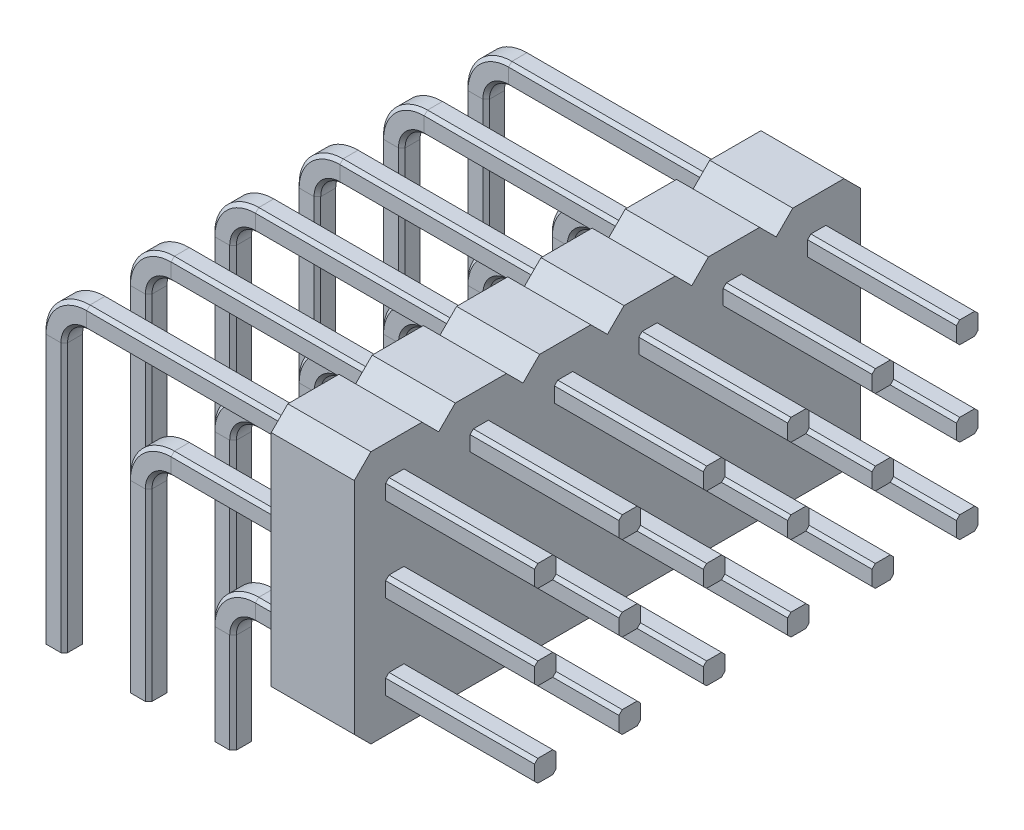
from build123d import *

# Parameters (mm, degrees)
BOSS_EXTRUDE1_DEPTH = 2.5
LPATTERN1_COUNT     = 6
LPATTERN1_PITCH     = 2.54


with BuildPart() as part:
    # Sweep1: sweep along a path in Sketch4
    with BuildLine(Plane.XY) as sweep1_path:
        Line((5.08, 0), (5.08, 3))
        ThreePointArc((5.08, 3), (5.372893219, 3.707106781), (6.08, 4))
        Line((6.08, 4), (14.48, 4))
    # Sketch3 → Sweep1 (sweep)
    with BuildSketch(Plane(origin=(0, 0, 0), x_dir=(1, 0, 0), z_dir=(0, 1, 0))):
        Polygon((5.305, 0.325), (4.855, 0.325), (4.755, 0.225), (4.755, -0.225), (4.855, -0.325), (5.305, -0.325), (5.405, -0.225), (5.405, 0.225), align=None)
    sweep(path=sweep1_path.line)



with BuildPart() as body_2:
    # Sweep2: sweep along a path in Sketch4_3
    with BuildLine(Plane.XY) as sweep2_path:
        Line((2.54, 0), (2.54, 5.54))
        ThreePointArc((2.54, 5.54), (2.832893219, 6.247106781), (3.54, 6.54))
        Line((3.54, 6.54), (14.48, 6.54))
    # Sketch3_3 → Sweep2 (sweep)
    with BuildSketch(Plane(origin=(0, 0, 0), x_dir=(1, 0, 0), z_dir=(0, 1, 0))):
        Polygon((2.765, 0.325), (2.315, 0.325), (2.215, 0.225), (2.215, -0.225), (2.315, -0.325), (2.765, -0.325), (2.865, -0.225), (2.865, 0.225), align=None)
    sweep(path=sweep2_path.line)


with BuildPart() as body_3:
    # Sweep3: sweep along a path in Sketch4_4
    with BuildLine(Plane.XY) as sweep3_path:
        Line((0, 0), (0, 8.08))
        ThreePointArc((0, 8.08), (0.292893219, 8.787106781), (1, 9.08))
        Line((1, 9.08), (14.48, 9.08))
    # Sketch3_4 → Sweep3 (sweep)
    with BuildSketch(Plane(origin=(0, 0, 0), x_dir=(1, 0, 0), z_dir=(0, 1, 0))):
        Polygon((-0.225, 0.325), (-0.325, 0.225), (-0.325, -0.225), (-0.225, -0.325), (0.225, -0.325), (0.325, -0.225), (0.325, 0.225), (0.225, 0.325), align=None)
    sweep(path=sweep3_path.line)


with BuildPart() as part_1:
    add(part.part)

    add(body_2.part)  # Boss-Extrude1 merges body 2

    add(body_3.part)  # Boss-Extrude1 merges body 3
    # Sketch5 → Boss-Extrude1 (add)
    with BuildSketch(Plane(origin=(7.5, 0, 0), x_dir=(0, 0, -1), z_dir=(1, 0, 0))):
        Polygon((-0.77, 2.73), (0.77, 2.73), (1.27, 3.23), (1.27, 9.85), (0.77, 10.35), (-0.77, 10.35), (-1.27, 9.85), (-1.27, 3.23), align=None)
    extrude(amount=BOSS_EXTRUDE1_DEPTH)


with BuildPart() as lpattern1_1:
    # LPattern1: pattern copy
    add(part_1.part.moved(Location(Vector(0, 0, -1) * (1 * LPATTERN1_PITCH))))


with BuildPart() as lpattern1_2:
    # LPattern1: pattern copy
    add(part_1.part.moved(Location(Vector(0, 0, -1) * (2 * LPATTERN1_PITCH))))


with BuildPart() as lpattern1_3:
    # LPattern1: pattern copy
    add(part_1.part.moved(Location(Vector(0, 0, -1) * (3 * LPATTERN1_PITCH))))


with BuildPart() as lpattern1_4:
    # LPattern1: pattern copy
    add(part_1.part.moved(Location(Vector(0, 0, -1) * (4 * LPATTERN1_PITCH))))


with BuildPart() as lpattern1_5:
    # LPattern1: pattern copy
    add(part_1.part.moved(Location(Vector(0, 0, -1) * (5 * LPATTERN1_PITCH))))


with BuildPart() as part_2:
    add(part_1.part)

    # Combine1: union LPattern1_1, LPattern1_2, LPattern1_3, LPattern1_4, LPattern1_5
    add(lpattern1_1.part)
    add(lpattern1_2.part)
    add(lpattern1_3.part)
    add(lpattern1_4.part)
    add(lpattern1_5.part)


solid = part_2.part
